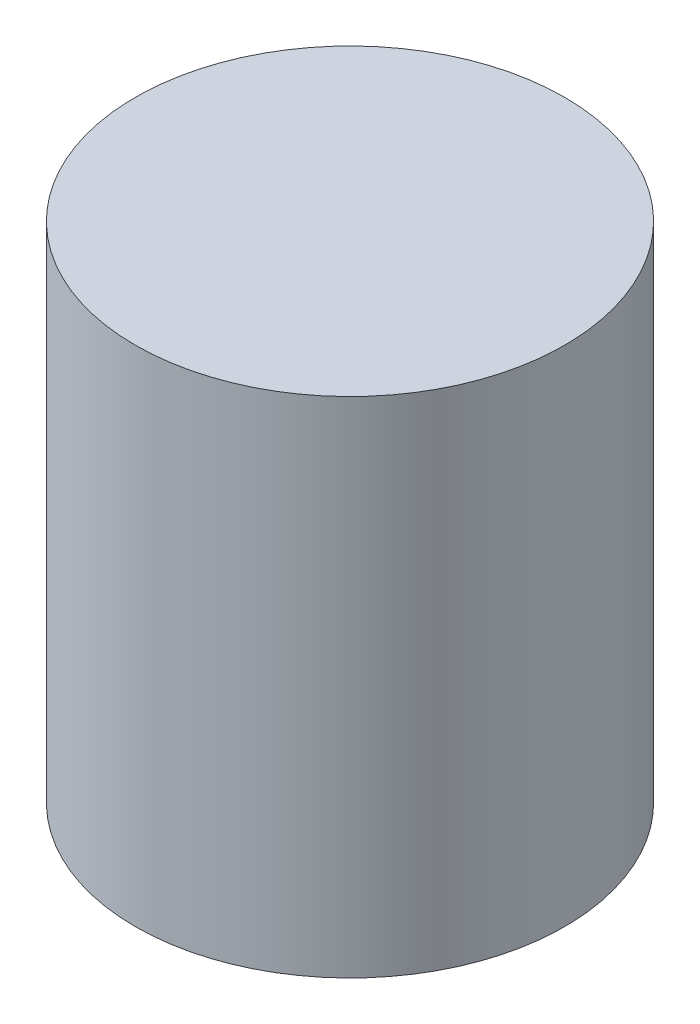
from build123d import *

# Parameters (mm, degrees)
SKETCH_1_R      = 4.05
SKETCH_1_R_2    = 3.05
EXTRUDE_1_DEPTH = 6
SKETCH_2_R      = 4.05
EXTRUDE_2_DEPTH = 3.5


with BuildPart() as part:
    # 스케치1 → 보스-돌출1 (new body)
    with BuildSketch(Plane(origin=(0, 0, 0), x_dir=(1, 0, 0), z_dir=(0, 1, 0))):
        Circle(SKETCH_1_R)
        Circle(SKETCH_1_R_2, mode=Mode.SUBTRACT)
    extrude(amount=EXTRUDE_1_DEPTH)

    # 스케치2 → 보스-돌출2 (add)
    with BuildSketch(Plane(origin=(0, 6, 0), x_dir=(1, 0, 0), z_dir=(0, 1, 0))):
        Circle(SKETCH_2_R)
    extrude(amount=EXTRUDE_2_DEPTH)


solid = part.part
